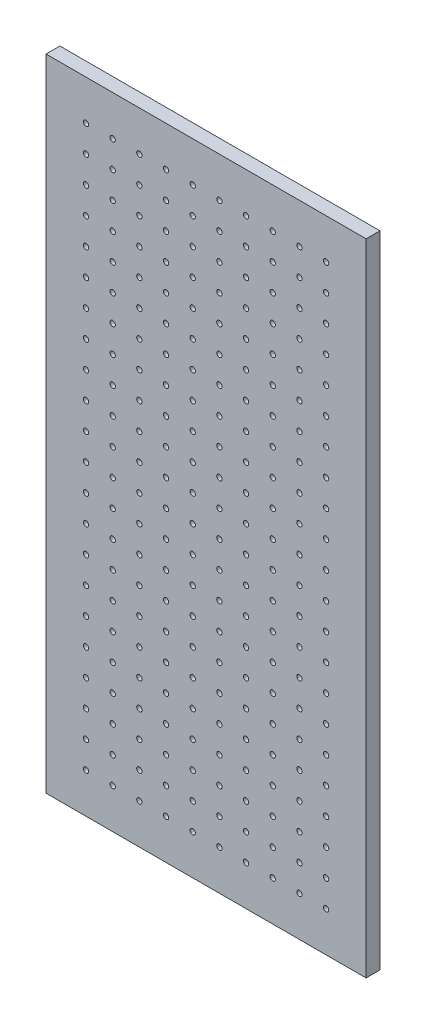
from build123d import *

# Parameters (mm, degrees)
SKETCH_1_W                  = 300
SKETCH_1_H                  = 600
EXTRUDE_1_DEPTH             = 13
HOLE_WIZARD_M6_1_D          = 5
PATTERN_LINEAR_1_COUNT      = 22
PATTERN_LINEAR_1_PITCH      = 25
PATTERN_LINEAR_1_COUNT_DIR2 = 10
PATTERN_LINEAR_1_PITCH_DIR2 = 25


with BuildPart() as part:
    # 草图1 → 凸台-拉伸1 (new body)
    with BuildSketch(Plane.XY):
        Rectangle(SKETCH_1_W, SKETCH_1_H)
    extrude(amount=EXTRUDE_1_DEPTH)

    # M6 螺纹孔的螺纹孔钻头1 (through all)
    with Locations(Plane.XY.offset(13)):
        with Locations((-112.5, -262.5)):
            hole_wizard_m6_1 = Hole(HOLE_WIZARD_M6_1_D / 2)

    # 阵列(线性)1: Hole Wizard M6 _1 22 × 10
    with Locations(*[(j * PATTERN_LINEAR_1_PITCH_DIR2, i * PATTERN_LINEAR_1_PITCH, 0) for i in range(PATTERN_LINEAR_1_COUNT) for j in range(PATTERN_LINEAR_1_COUNT_DIR2) if (i, j) != (0, 0)]):
        add(hole_wizard_m6_1, mode=Mode.SUBTRACT)


solid = part.part
